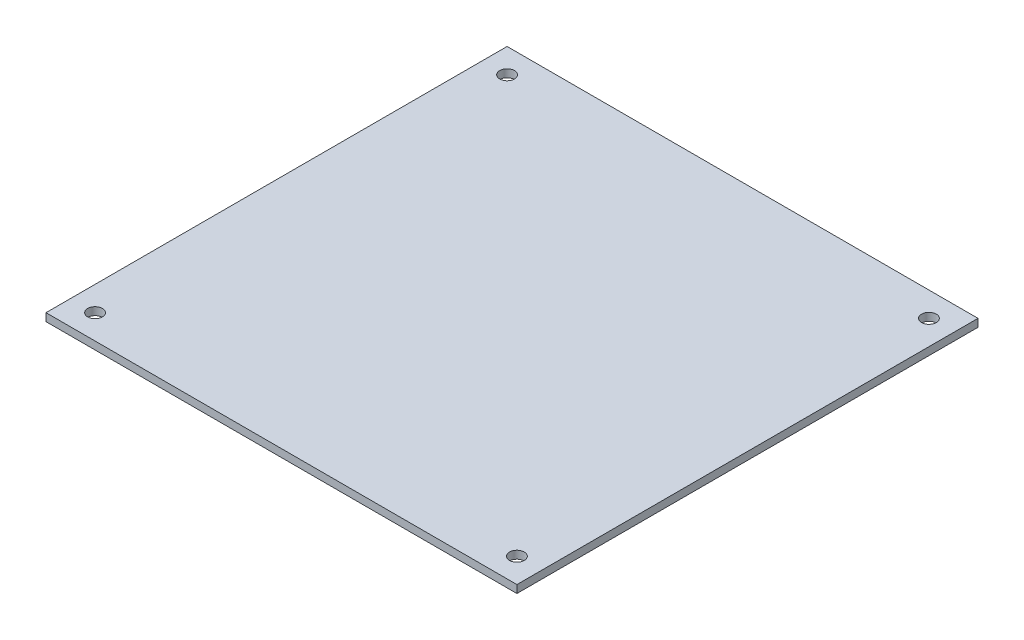
from build123d import *

# Parameters (mm, degrees)
SKETCH1_W           = 96
SKETCH1_H           = 94
BOSS_EXTRUDE1_DEPTH = 1.5875
SKETCH2_R           = 1.5
CUT_EXTRUDE1_DEPTH  = 2.5875


with BuildPart() as part:
    # Sketch1 → Boss-Extrude1 (new body)
    with BuildSketch(Plane(origin=(0, 0, 0), x_dir=(1, 0, 0), z_dir=(0, 1, 0))):
        Rectangle(SKETCH1_W, SKETCH1_H)
    extrude(amount=BOSS_EXTRUDE1_DEPTH)

    # Sketch2 → Cut-Extrude1 (cut, through all)
    with BuildSketch(Plane(origin=(0, 1.5875, 0), x_dir=(1, 0, 0), z_dir=(0, 1, 0))):
        with Locations((-43, 42)):
            Circle(SKETCH2_R)
        with Locations((43, 42)):
            Circle(SKETCH2_R)
        with Locations((43, -42)):
            Circle(SKETCH2_R)
        with Locations((-43, -42)):
            Circle(SKETCH2_R)
    extrude(amount=-CUT_EXTRUDE1_DEPTH, mode=Mode.SUBTRACT)


solid = part.part
